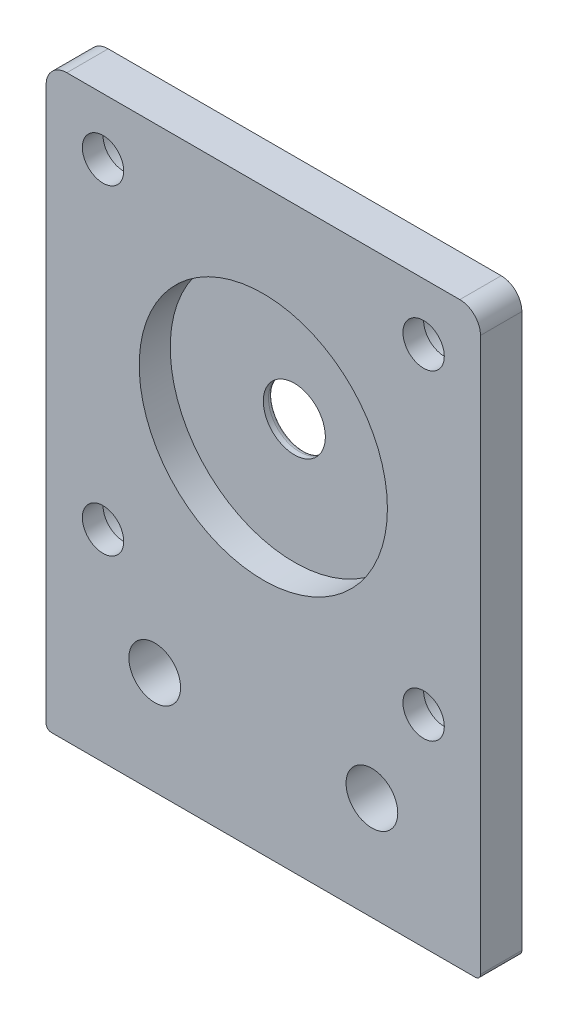
from build123d import *

# Parameters (mm, degrees)
SKETCH1_R           = 2.999999999
BOSS_EXTRUDE1_DEPTH = 4
SKETCH5_R           = 12
CUT_EXTRUDE1_DEPTH  = 3
FILLET1_R           = 2
FILLET2_R           = 0.5
FILLET3_R           = 0.5
SKETCH6_R           = 2.5
CUT_EXTRUDE2_DEPTH  = 10
SKETCH7_R           = 2
CUT_EXTRUDE3_DEPTH  = 10
SKETCH8_R           = 3.5
CUT_EXTRUDE4_DEPTH  = 2


with BuildPart() as part:
    # Sketch1 → Boss-Extrude1 (new body)
    with BuildSketch(Plane.XY):
        Polygon((0, 0), (42, 0), (42, 51.371572875), (42, 56), (37.371572875, 56), (4.628427125, 56), (0, 56), align=None)
        with Locations((21, 35)):
            Circle(SKETCH1_R, mode=Mode.SUBTRACT)
    extrude(amount=BOSS_EXTRUDE1_DEPTH)

    # Sketch5 → Cut-Extrude1 (cut)
    with BuildSketch(Plane.XY.offset(4)):
        with Locations((21, 35)):
            Circle(SKETCH5_R)
    extrude(amount=-CUT_EXTRUDE1_DEPTH, mode=Mode.SUBTRACT)

    # Fillet1
    fillet1_edges = [part.edges().sort_by_distance(p)[0] for p in [
        (0, 56, 2),
        (42, 56, 2),
    ]]
    fillet(fillet1_edges, radius=FILLET1_R)

    # Fillet2
    fillet2_edges = [part.edges().sort_by_distance(p)[0] for p in [
        (42, 0, 2),
        (0, 0, 2),
    ]]
    fillet(fillet2_edges, radius=FILLET2_R)

    # Fillet3
    fillet3_edges = [part.edges().sort_by_distance(p)[0] for p in [
        (18.000000001, 35, 0),
    ]]
    fillet(fillet3_edges, radius=FILLET3_R)

    # Sketch6 → Cut-Extrude2 (cut)
    with BuildSketch(Plane.XY.offset(4)):
        with Locations((10.5, 10)):
            Circle(SKETCH6_R)
        with Locations((31.5, 10)):
            Circle(SKETCH6_R)
    extrude(amount=-CUT_EXTRUDE2_DEPTH, mode=Mode.SUBTRACT)

    # Sketch7 → Cut-Extrude3 (cut)
    with BuildSketch(Plane.XY.offset(4)):
        with Locations((5.5, 50.5)):
            Circle(SKETCH7_R)
        with Locations((5.5, 19.5)):
            Circle(SKETCH7_R)
        with Locations((36.5, 19.5)):
            Circle(SKETCH7_R)
        with Locations((36.5, 50.5)):
            Circle(SKETCH7_R)
    extrude(amount=-CUT_EXTRUDE3_DEPTH, mode=Mode.SUBTRACT)

    # Sketch8 → Cut-Extrude4 (cut)
    with BuildSketch(Plane(origin=(0, 0, 0), x_dir=(-1, 0, 0), z_dir=(0, 0, -1))):
        with Locations((-36.5, 50.5)):
            Circle(SKETCH8_R)
        with Locations((-36.5, 19.5)):
            Circle(SKETCH8_R)
        with Locations((-5.5, 19.5)):
            Circle(SKETCH8_R)
        with Locations((-5.5, 50.5)):
            Circle(SKETCH8_R)
    extrude(amount=-CUT_EXTRUDE4_DEPTH, mode=Mode.SUBTRACT)


solid = part.part
